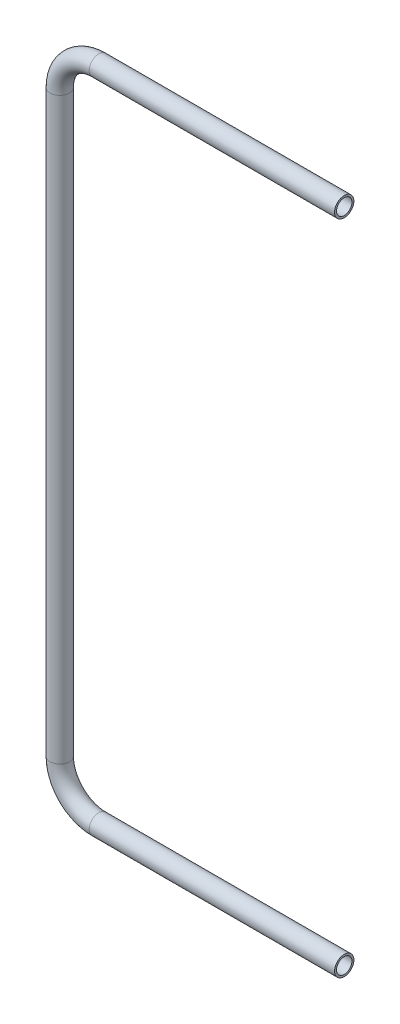
from build123d import *

# Parameters (mm, degrees)
SKETCH2_R   = 16.7005
SKETCH2_R_2 = 13.335


with BuildPart() as part:
    # Sweep1: sweep along a path in Sketch1
    with BuildLine(Plane.XY) as sweep1_path:
        Line((0, 0), (-423.799, 0))
        ThreePointArc((-423.799, 0), (-471.529061283, 19.770438717), (-491.2995, 67.5005))
        Line((-491.2995, 67.5005), (-491.2995, 1067.562))
        ThreePointArc((-491.2995, 1067.562), (-471.529061283, 1115.292061283), (-423.799, 1135.0625))
        Line((-423.799, 1135.0625), (0, 1135.0625))
    # Sketch2 → Sweep1 (sweep)
    with BuildSketch(Plane(origin=(0, 0, 0), x_dir=(0, 0, -1), z_dir=(1, 0, 0))):
        Circle(SKETCH2_R)
        Circle(SKETCH2_R_2, mode=Mode.SUBTRACT)
    sweep(path=sweep1_path.line)


solid = part.part
